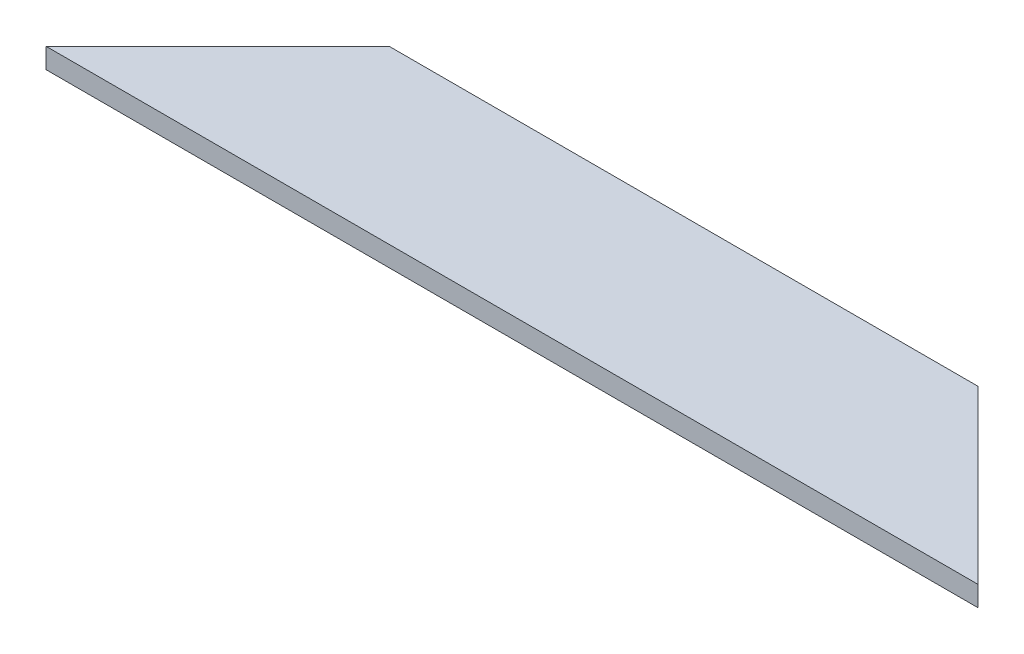
from build123d import *

# Parameters (mm, degrees)
BOSS_EXTRUDE1_DEPTH = 3


with BuildPart() as part:
    # Sketch1 → Boss-Extrude1 (new body)
    with BuildSketch(Plane(origin=(0, 0, 0), x_dir=(1, 0, 0), z_dir=(0, 1, 0))):
        Polygon((-92.503163169, -30.438905326), (-67.103163169, -5.038905326), (20.096836831, -5.038905326), (45.496836831, -30.438905326), align=None)
    extrude(amount=BOSS_EXTRUDE1_DEPTH)


solid = part.part
